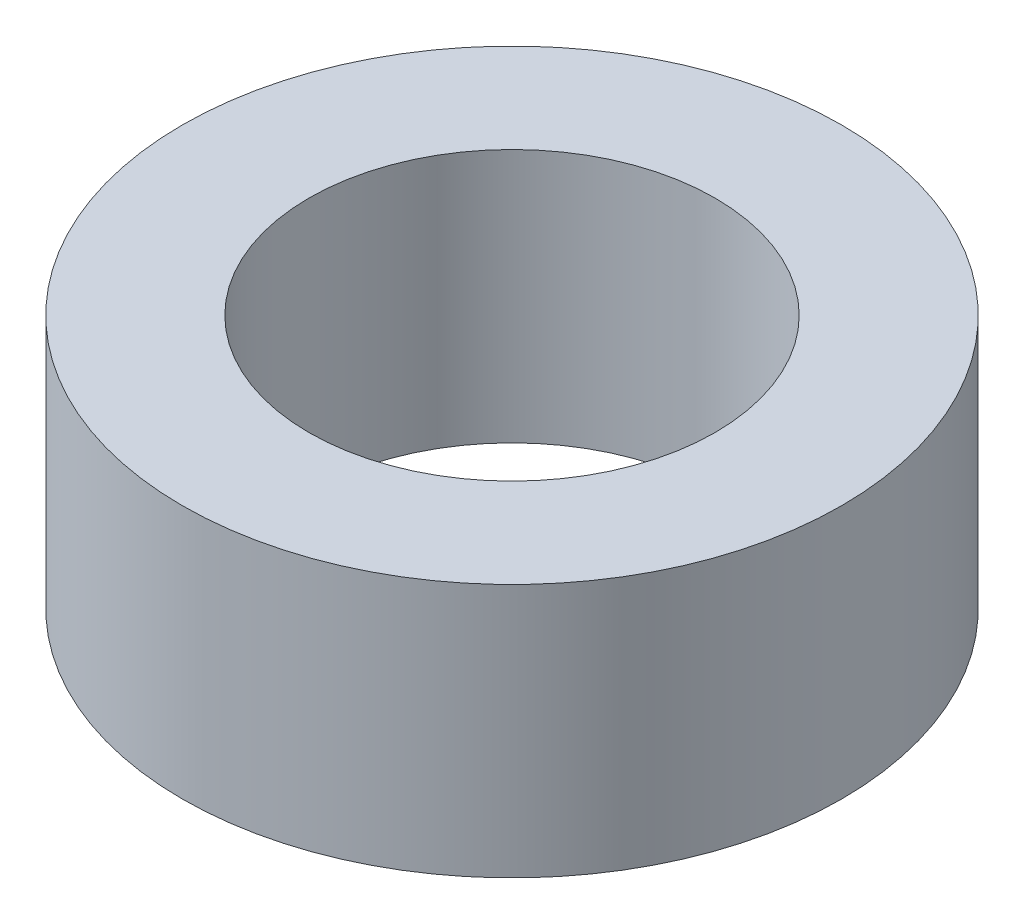
from build123d import *

# Parameters (mm, degrees)
SKETCH1_R           = 4.7625
SKETCH1_R_2         = 2.9337
BOSS_EXTRUDE1_DEPTH = 3.6703


with BuildPart() as part:
    # Sketch1 → Boss-Extrude1 (new body)
    with BuildSketch(Plane(origin=(0, 0, 0), x_dir=(1, 0, 0), z_dir=(0, 1, 0))):
        Circle(SKETCH1_R)
        Circle(SKETCH1_R_2, mode=Mode.SUBTRACT)
    extrude(amount=BOSS_EXTRUDE1_DEPTH)


solid = part.part
